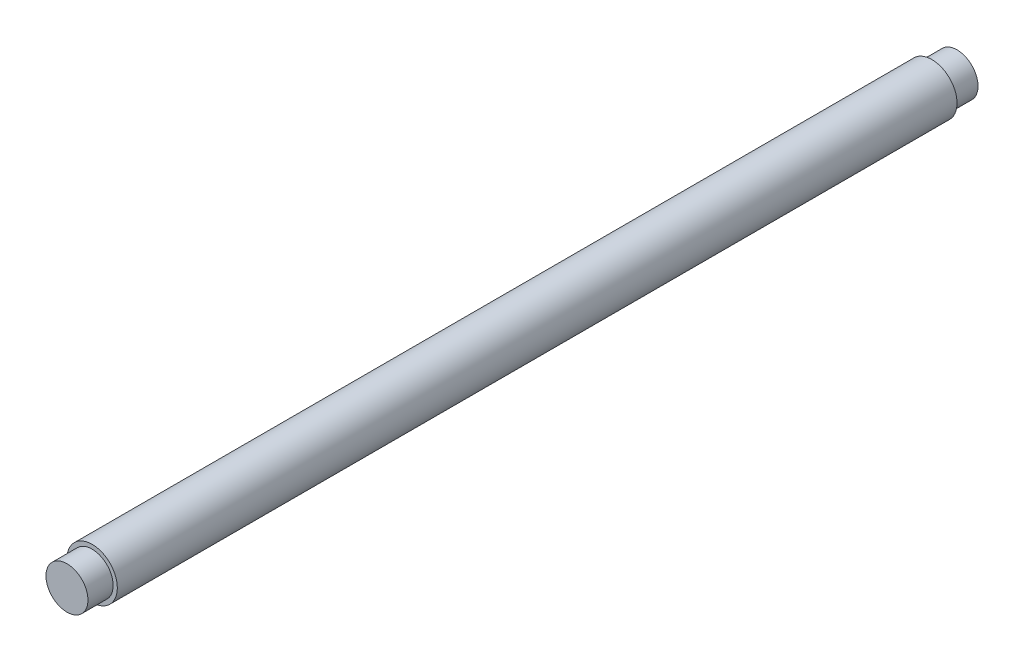
from build123d import *

# Parameters (mm, degrees)
SKETCH2_R                = 3
BOSS_EXTRUDE1_DEPTH      = 75
BOSS_EXTRUDE1_DEPTH_BACK = 75
CHAMFER1_SIZE            = 0.12
SKETCH4_R                = 3
CUT_EXTRUDE1_DEPTH       = 44
SKETCH5_OUTSIDE_W        = 29.268
SKETCH5_OUTSIDE_H        = 29.268
SKETCH5_OUTSIDE_R        = 2.5
CUT_EXTRUDE2_DEPTH       = 3
SKETCH6_OUTSIDE_W        = 29.268
SKETCH6_OUTSIDE_H        = 29.268
SKETCH6_OUTSIDE_R        = 2.5
CUT_EXTRUDE3_DEPTH       = 3


with BuildPart() as part:
    # Sketch2 → Boss-Extrude1 (new body, two sides)
    with BuildSketch(Plane.XY) as boss_extrude1_sk:
        Circle(SKETCH2_R)
    extrude(amount=BOSS_EXTRUDE1_DEPTH)
    extrude(boss_extrude1_sk.sketch, amount=-BOSS_EXTRUDE1_DEPTH_BACK)

    # Chamfer1
    chamfer1_edges = [part.edges().sort_by_distance(p)[0] for p in [
        (-3, 0, -75),
        (-3, 0, 75),
    ]]
    chamfer(chamfer1_edges, length=CHAMFER1_SIZE)

    # Sketch4 → Cut-Extrude1 (cut)
    with BuildSketch(Plane(origin=(0, 0, -75), x_dir=(-1, 0, 0), z_dir=(0, 0, -1))):
        Circle(SKETCH4_R)
    extrude(amount=-CUT_EXTRUDE1_DEPTH, mode=Mode.SUBTRACT)

    # Sketch5 outside → Cut-Extrude2 (cut)
    with BuildSketch(Plane(origin=(0, 0, -31), x_dir=(-1, 0, 0), z_dir=(0, 0, -1))):
        Rectangle(SKETCH5_OUTSIDE_W, SKETCH5_OUTSIDE_H)
        Circle(SKETCH5_OUTSIDE_R, mode=Mode.SUBTRACT)
    extrude(amount=-CUT_EXTRUDE2_DEPTH, mode=Mode.SUBTRACT)

    # Sketch6 outside → Cut-Extrude3 (cut)
    with BuildSketch(Plane.XY.offset(75)):
        Rectangle(SKETCH6_OUTSIDE_W, SKETCH6_OUTSIDE_H)
        Circle(SKETCH6_OUTSIDE_R, mode=Mode.SUBTRACT)
    extrude(amount=-CUT_EXTRUDE3_DEPTH, mode=Mode.SUBTRACT)


solid = part.part
